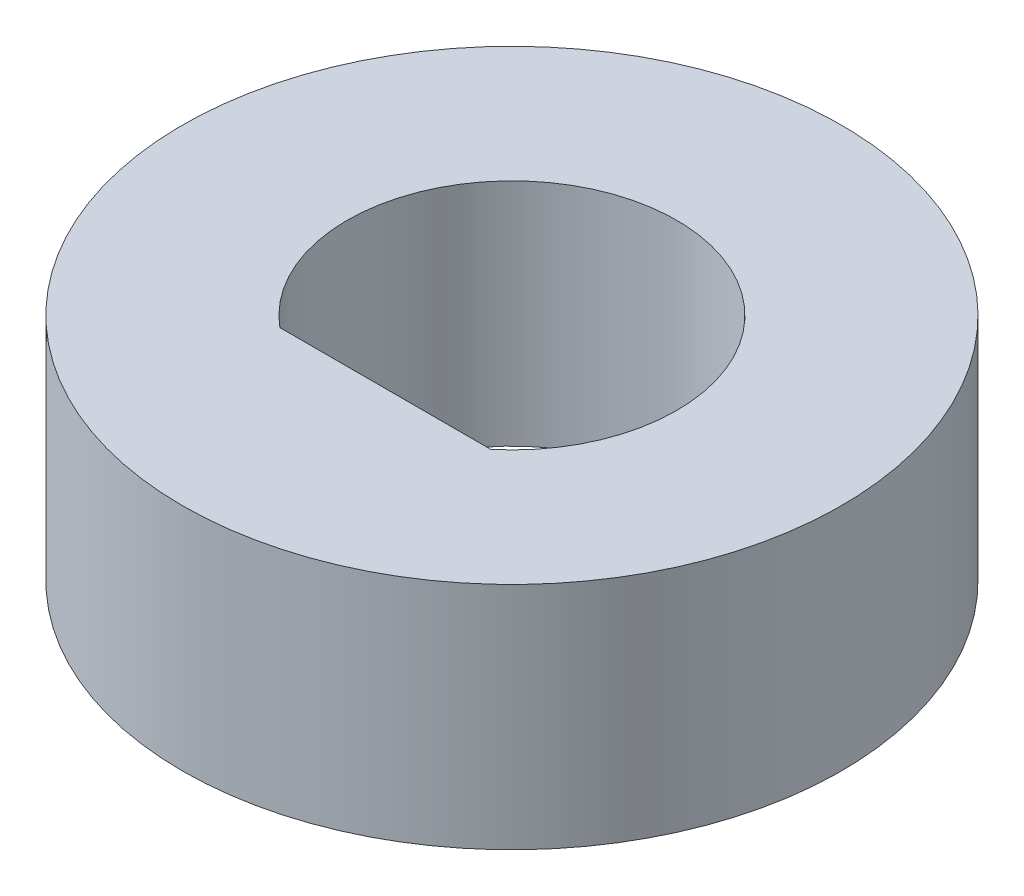
from build123d import *

# Parameters (mm, degrees)
SKETCH1_R           = 6.35
BOSS_EXTRUDE1_DEPTH = 76.2
SKETCH2_R           = 6.35
CUT_EXTRUDE1_DEPTH  = 71.77278


with BuildPart() as part:
    # Sketch1 → Boss-Extrude1 (new body)
    with BuildSketch(Plane(origin=(0, 0, 0), x_dir=(1, 0, 0), z_dir=(0, 1, 0))):
        Circle(SKETCH1_R)
        with BuildLine():
            Line((2.032, -2.439590334), (-2.032, -2.439590334))
            ThreePointArc((-2.032, -2.439590334), (0, 3.175), (2.032, -2.439590334))
        make_face(mode=Mode.SUBTRACT)
    extrude(amount=BOSS_EXTRUDE1_DEPTH)

    # Sketch2 → Cut-Extrude1 (cut)
    with BuildSketch(Plane(origin=(0, 76.2, 0), x_dir=(1, 0, 0), z_dir=(0, 1, 0))):
        Circle(SKETCH2_R)
    extrude(amount=-CUT_EXTRUDE1_DEPTH, mode=Mode.SUBTRACT)


solid = part.part
